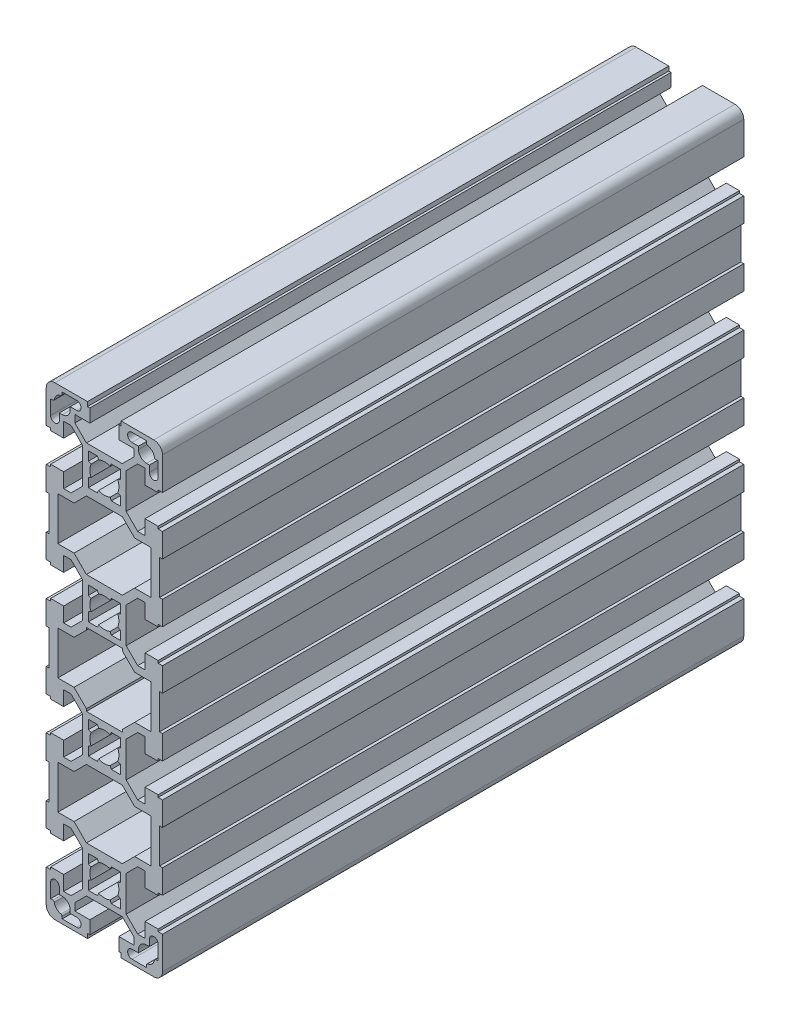
from build123d import *

# Parameters (mm, degrees)
EXTRUDE1_DEPTH = 200


with BuildPart() as part:
    # Sketch1 → Extrude1 (new body)
    with BuildSketch(Plane.XY):
        with BuildLine():
            Line((19, -34), (20, -34))
            Line((20, -34), (20, -25.8))
            Line((20, -25.8), (18.5, -25.8))
            Line((18.5, -25.8), (18.5, -25))
            Line((18.5, -25), (14, -25))
            Line((14, -25), (14, -30.05))
            Line((14, -30.05), (11.464213562, -30.05))
            Line((11.464213562, -30.05), (7.5, -26.085786438))
            Line((7.5, -26.085786438), (7.5, -13.914213562))
            Line((7.5, -13.914213562), (11.464213562, -9.95))
            Line((11.464213562, -9.95), (14, -9.95))
            Line((14, -9.95), (14, -15))
            Line((14, -15), (18.5, -15))
            Line((18.5, -15), (18.5, -14.2))
            Line((18.5, -14.2), (20, -14.2))
            Line((20, -14.2), (20, -6))
            Line((20, -6), (19, -6))
            Line((19, -6), (19, 6))
            Line((19, 6), (20, 6))
            Line((20, 6), (20, 14.2))
            Line((20, 14.2), (18.5, 14.2))
            Line((18.5, 14.2), (18.5, 15))
            Line((18.5, 15), (14, 15))
            Line((14, 15), (14, 9.95))
            Line((14, 9.95), (11.464213562, 9.95))
            Line((11.464213562, 9.95), (7.5, 13.914213562))
            Line((7.5, 13.914213562), (7.5, 26.085786438))
            Line((7.5, 26.085786438), (11.464213562, 30.05))
            Line((11.464213562, 30.05), (14, 30.05))
            Line((14, 30.05), (14, 25))
            Line((14, 25), (18.5, 25))
            Line((18.5, 25), (18.5, 25.8))
            Line((18.5, 25.8), (20, 25.8))
            Line((20, 25.8), (20, 34))
            Line((20, 34), (19, 34))
            Line((19, 34), (19, 46))
            Line((19, 46), (20, 46))
            Line((20, 46), (20, 54.2))
            Line((20, 54.2), (18.5, 54.2))
            Line((18.5, 54.2), (18.5, 55))
            Line((18.5, 55), (14, 55))
            Line((14, 55), (14, 49.95))
            Line((14, 49.95), (11.464213562, 49.95))
            Line((11.464213562, 49.95), (7.5, 53.914213562))
            Line((7.5, 53.914213562), (7.5, 66.085786438))
            Line((7.5, 66.085786438), (11.464213562, 70.05))
            Line((11.464213562, 70.05), (14, 70.05))
            Line((14, 70.05), (14, 65))
            Line((14, 65), (18.5, 65))
            Line((18.5, 65), (18.5, 65.8))
            Line((18.5, 65.8), (20, 65.8))
            Line((20, 65.8), (20, 77))
            ThreePointArc((20, 77), (19.121320344, 79.121320344), (17, 80))
            Line((17, 80), (5.8, 80))
            Line((5.8, 80), (5.8, 78.5))
            Line((5.8, 78.5), (5, 78.5))
            Line((5, 78.5), (5, 73.994624839))
            Line((5, 73.994624839), (10.142893219, 73.994624839))
            Line((10.142893219, 73.994624839), (10.142893219, 71.458838401))
            Line((10.142893219, 71.458838401), (6.178679656, 67.494624839))
            Line((6.178679656, 67.494624839), (-6.178679656, 67.494624839))
            Line((-6.178679656, 67.494624839), (-10.142893219, 71.458838401))
            Line((-10.142893219, 71.458838401), (-10.142893219, 73.994624839))
            Line((-10.142893219, 73.994624839), (-5, 73.994624839))
            Line((-5, 73.994624839), (-5, 78.5))
            Line((-5, 78.5), (-5.8, 78.5))
            Line((-5.8, 78.5), (-5.8, 80))
            Line((-5.8, 80), (-17, 80))
            ThreePointArc((-17, 80), (-19.121320344, 79.121320344), (-20, 77))
            Line((-20, 77), (-20, 65.8))
            Line((-20, 65.8), (-18.5, 65.8))
            Line((-18.5, 65.8), (-18.5, 65))
            Line((-18.5, 65), (-14, 65))
            Line((-14, 65), (-14, 70.05))
            Line((-14, 70.05), (-11.464213562, 70.05))
            Line((-11.464213562, 70.05), (-7.5, 66.085786438))
            Line((-7.5, 66.085786438), (-7.5, 53.914213562))
            Line((-7.5, 53.914213562), (-11.464213562, 49.95))
            Line((-11.464213562, 49.95), (-14, 49.95))
            Line((-14, 49.95), (-14, 55))
            Line((-14, 55), (-18.5, 55))
            Line((-18.5, 55), (-18.5, 54.2))
            Line((-18.5, 54.2), (-20, 54.2))
            Line((-20, 54.2), (-20, 46))
            Line((-20, 46), (-19, 46))
            Line((-19, 46), (-19, 34))
            Line((-19, 34), (-20, 34))
            Line((-20, 34), (-20, 25.8))
            Line((-20, 25.8), (-18.5, 25.8))
            Line((-18.5, 25.8), (-18.5, 25))
            Line((-18.5, 25), (-14, 25))
            Line((-14, 25), (-14, 30.05))
            Line((-14, 30.05), (-11.464213562, 30.05))
            Line((-11.464213562, 30.05), (-7.5, 26.085786438))
            Line((-7.5, 26.085786438), (-7.5, 13.914213562))
            Line((-7.5, 13.914213562), (-11.464213562, 9.95))
            Line((-11.464213562, 9.95), (-14, 9.95))
            Line((-14, 9.95), (-14, 15))
            Line((-14, 15), (-18.5, 15))
            Line((-18.5, 15), (-18.5, 14.2))
            Line((-18.5, 14.2), (-20, 14.2))
            Line((-20, 14.2), (-20, 6))
            Line((-20, 6), (-19, 6))
            Line((-19, 6), (-19, -6))
            Line((-19, -6), (-20, -6))
            Line((-20, -6), (-20, -14.2))
            Line((-20, -14.2), (-18.5, -14.2))
            Line((-18.5, -14.2), (-18.5, -15))
            Line((-18.5, -15), (-14, -15))
            Line((-14, -15), (-14, -9.95))
            Line((-14, -9.95), (-11.464213562, -9.95))
            Line((-11.464213562, -9.95), (-7.5, -13.914213562))
            Line((-7.5, -13.914213562), (-7.5, -26.085786438))
            Line((-7.5, -26.085786438), (-11.464213562, -30.05))
            Line((-11.464213562, -30.05), (-14, -30.05))
            Line((-14, -30.05), (-14, -25))
            Line((-14, -25), (-18.5, -25))
            Line((-18.5, -25), (-18.5, -25.8))
            Line((-18.5, -25.8), (-20, -25.8))
            Line((-20, -25.8), (-20, -34))
            Line((-20, -34), (-19, -34))
            Line((-19, -34), (-19, -46))
            Line((-19, -46), (-20, -46))
            Line((-20, -46), (-20, -54.2))
            Line((-20, -54.2), (-18.5, -54.2))
            Line((-18.5, -54.2), (-18.5, -55))
            Line((-18.5, -55), (-14, -55))
            Line((-14, -55), (-14, -49.95))
            Line((-14, -49.95), (-11.464213562, -49.95))
            Line((-11.464213562, -49.95), (-7.5, -53.914213562))
            Line((-7.5, -53.914213562), (-7.5, -66.085786438))
            Line((-7.5, -66.085786438), (-11.464213562, -70.05))
            Line((-11.464213562, -70.05), (-14, -70.05))
            Line((-14, -70.05), (-14, -65))
            Line((-14, -65), (-18.5, -65))
            Line((-18.5, -65), (-18.5, -65.8))
            Line((-18.5, -65.8), (-20, -65.8))
            Line((-20, -65.8), (-20, -77))
            ThreePointArc((-20, -77), (-19.121320344, -79.121320344), (-17, -80))
            Line((-17, -80), (-5.8, -80))
            Line((-5.8, -80), (-5.8, -78.5))
            Line((-5.8, -78.5), (-5, -78.5))
            Line((-5, -78.5), (-5, -73.994624839))
            Line((-5, -73.994624839), (-10.142893219, -73.994624839))
            Line((-10.142893219, -73.994624839), (-10.142893219, -71.458838401))
            Line((-10.142893219, -71.458838401), (-6.178679656, -67.494624839))
            Line((-6.178679656, -67.494624839), (6.178679656, -67.494624839))
            Line((6.178679656, -67.494624839), (10.142893219, -71.458838401))
            Line((10.142893219, -71.458838401), (10.142893219, -73.994624839))
            Line((10.142893219, -73.994624839), (5, -73.994624839))
            Line((5, -73.994624839), (5, -78.5))
            Line((5, -78.5), (5.8, -78.5))
            Line((5.8, -78.5), (5.8, -80))
            Line((5.8, -80), (17, -80))
            ThreePointArc((17, -80), (19.121320344, -79.121320344), (20, -77))
            Line((20, -77), (20, -65.8))
            Line((20, -65.8), (18.5, -65.8))
            Line((18.5, -65.8), (18.5, -65))
            Line((18.5, -65), (14, -65))
            Line((14, -65), (14, -70.05))
            Line((14, -70.05), (11.464213562, -70.05))
            Line((11.464213562, -70.05), (7.5, -66.085786438))
            Line((7.5, -66.085786438), (7.5, -53.914213562))
            Line((7.5, -53.914213562), (11.464213562, -49.95))
            Line((11.464213562, -49.95), (14, -49.95))
            Line((14, -49.95), (14, -55))
            Line((14, -55), (18.5, -55))
            Line((18.5, -55), (18.5, -54.2))
            Line((18.5, -54.2), (20, -54.2))
            Line((20, -54.2), (20, -46))
            Line((20, -46), (19, -46))
            Line((19, -46), (19, -34))
        make_face()
        Polygon((10.428679656, -32.55), (6.178679656, -28.3), (-6.178679656, -28.3), (-10.428679656, -32.55), (-16, -32.55), (-16, -47.45), (-10.428679656, -47.45), (-6.178679656, -51.7), (6.178679656, -51.7), (10.428679656, -47.45), (16, -47.45), (16, -32.55), align=None, mode=Mode.SUBTRACT)
        with BuildLine():
            Line((2.397915762, -25.5), (5.5, -25.5))
            Line((5.5, -25.5), (5.5, -22.397915762))
            Line((5.5, -22.397915762), (4.583333333, -21.998263135))
            ThreePointArc((4.583333333, -21.998263135), (5, -20), (4.583333333, -18.001736865))
            Line((4.583333333, -18.001736865), (5.5, -17.602084238))
            Line((5.5, -17.602084238), (5.5, -14.5))
            Line((5.5, -14.5), (2.397915762, -14.5))
            Line((2.397915762, -14.5), (1.998263135, -15.416666667))
            ThreePointArc((1.998263135, -15.416666667), (0, -15), (-1.998263135, -15.416666667))
            Line((-1.998263135, -15.416666667), (-2.397915762, -14.5))
            Line((-2.397915762, -14.5), (-5.5, -14.5))
            Line((-5.5, -14.5), (-5.5, -17.602084238))
            Line((-5.5, -17.602084238), (-4.583333333, -18.001736865))
            ThreePointArc((-4.583333333, -18.001736865), (-5, -20), (-4.583333333, -21.998263135))
            Line((-4.583333333, -21.998263135), (-5.5, -22.397915762))
            Line((-5.5, -22.397915762), (-5.5, -25.5))
            Line((-5.5, -25.5), (-2.397915762, -25.5))
            Line((-2.397915762, -25.5), (-1.998263135, -24.583333333))
            ThreePointArc((-1.998263135, -24.583333333), (0, -25), (1.998263135, -24.583333333))
            Line((1.998263135, -24.583333333), (2.397915762, -25.5))
        make_face(mode=Mode.SUBTRACT)
        Polygon((10.428679656, -7.45), (6.178679656, -11.7), (6.178679656, -12.505375161), (-6.178679656, -12.505375161), (-6.178679656, -11.7), (-10.428679656, -7.45), (-16, -7.45), (-16, 7.45), (-10.428679656, 7.45), (-6.178679656, 11.7), (-6.178679656, 12.505375161), (6.178679656, 12.505375161), (6.178679656, 11.7), (10.428679656, 7.45), (16, 7.45), (16, -7.45), align=None, mode=Mode.SUBTRACT)
        Polygon((16, 32.55), (16, 47.45), (10.428679656, 47.45), (6.178679656, 51.7), (-6.178679656, 51.7), (-10.428679656, 47.45), (-16, 47.45), (-16, 32.55), (-10.428679656, 32.55), (-6.178679656, 28.3), (6.178679656, 28.3), (10.428679656, 32.55), align=None, mode=Mode.SUBTRACT)
        with BuildLine():
            Line((18.5, 74.5), (17.711308145, 74.5))
            ThreePointArc((17.711308145, 74.5), (17.386086327, 74.620222737), (17.217260738, 74.923076923))
            ThreePointArc((17.217260738, 74.923076923), (16.444543648, 76.444543648), (14.923076923, 77.217260738))
            ThreePointArc((14.923076923, 77.217260738), (14.620222737, 77.386086327), (14.5, 77.711308145))
            Line((14.5, 77.711308145), (14.5, 78.5))
            Line((14.5, 78.5), (9.5, 78.5))
            ThreePointArc((9.5, 78.5), (8, 77), (9.5, 75.5))
            Line((9.5, 75.5), (11.75, 75.5))
            Line((11.75, 75.5), (11.75, 74.5))
            ThreePointArc((11.75, 74.5), (12.555456352, 72.555456352), (14.5, 71.75))
            Line((14.5, 71.75), (15.5, 71.75))
            Line((15.5, 71.75), (15.5, 69.5))
            ThreePointArc((15.5, 69.5), (17, 68), (18.5, 69.5))
            Line((18.5, 69.5), (18.5, 74.5))
        make_face(mode=Mode.SUBTRACT)
        with BuildLine():
            Line((2.397915762, 54.5), (5.5, 54.5))
            Line((5.5, 54.5), (5.5, 57.602084238))
            Line((5.5, 57.602084238), (4.583333333, 58.001736865))
            ThreePointArc((4.583333333, 58.001736865), (5, 60), (4.583333333, 61.998263135))
            Line((4.583333333, 61.998263135), (5.5, 62.397915762))
            Line((5.5, 62.397915762), (5.5, 65.5))
            Line((5.5, 65.5), (2.397915762, 65.5))
            Line((2.397915762, 65.5), (1.998263135, 64.583333333))
            ThreePointArc((1.998263135, 64.583333333), (0, 65), (-1.998263135, 64.583333333))
            Line((-1.998263135, 64.583333333), (-2.397915762, 65.5))
            Line((-2.397915762, 65.5), (-5.5, 65.5))
            Line((-5.5, 65.5), (-5.5, 62.397915762))
            Line((-5.5, 62.397915762), (-4.583333333, 61.998263135))
            ThreePointArc((-4.583333333, 61.998263135), (-5, 60), (-4.583333333, 58.001736865))
            Line((-4.583333333, 58.001736865), (-5.5, 57.602084238))
            Line((-5.5, 57.602084238), (-5.5, 54.5))
            Line((-5.5, 54.5), (-2.397915762, 54.5))
            Line((-2.397915762, 54.5), (-1.998263135, 55.416666667))
            ThreePointArc((-1.998263135, 55.416666667), (0, 55), (1.998263135, 55.416666667))
            Line((1.998263135, 55.416666667), (2.397915762, 54.5))
        make_face(mode=Mode.SUBTRACT)
        with BuildLine():
            Line((-17.711308145, 74.5), (-18.5, 74.5))
            Line((-18.5, 74.5), (-18.5, 69.5))
            ThreePointArc((-18.5, 69.5), (-17, 68), (-15.5, 69.5))
            Line((-15.5, 69.5), (-15.5, 71.75))
            Line((-15.5, 71.75), (-14.5, 71.75))
            ThreePointArc((-14.5, 71.75), (-12.555456352, 72.555456352), (-11.75, 74.5))
            Line((-11.75, 74.5), (-11.75, 75.5))
            Line((-11.75, 75.5), (-9.5, 75.5))
            ThreePointArc((-9.5, 75.5), (-8, 77), (-9.5, 78.5))
            Line((-9.5, 78.5), (-14.5, 78.5))
            Line((-14.5, 78.5), (-14.5, 77.711308145))
            ThreePointArc((-14.5, 77.711308145), (-14.620222737, 77.386086327), (-14.923076923, 77.217260738))
            ThreePointArc((-14.923076923, 77.217260738), (-16.444543648, 76.444543648), (-17.217260738, 74.923076923))
            ThreePointArc((-17.217260738, 74.923076923), (-17.386086327, 74.620222737), (-17.711308145, 74.5))
        make_face(mode=Mode.SUBTRACT)
        with BuildLine():
            Line((5.5, 17.602084238), (5.5, 14.5))
            Line((5.5, 14.5), (2.397915762, 14.5))
            Line((2.397915762, 14.5), (1.998263135, 15.416666667))
            ThreePointArc((1.998263135, 15.416666667), (0, 15), (-1.998263135, 15.416666667))
            Line((-1.998263135, 15.416666667), (-2.397915762, 14.5))
            Line((-2.397915762, 14.5), (-5.5, 14.5))
            Line((-5.5, 14.5), (-5.5, 17.602084238))
            Line((-5.5, 17.602084238), (-4.583333333, 18.001736865))
            ThreePointArc((-4.583333333, 18.001736865), (-5, 20), (-4.583333333, 21.998263135))
            Line((-4.583333333, 21.998263135), (-5.5, 22.397915762))
            Line((-5.5, 22.397915762), (-5.5, 25.5))
            Line((-5.5, 25.5), (-2.397915762, 25.5))
            Line((-2.397915762, 25.5), (-1.998263135, 24.583333333))
            ThreePointArc((-1.998263135, 24.583333333), (0, 25), (1.998263135, 24.583333333))
            Line((1.998263135, 24.583333333), (2.397915762, 25.5))
            Line((2.397915762, 25.5), (5.5, 25.5))
            Line((5.5, 25.5), (5.5, 22.397915762))
            Line((5.5, 22.397915762), (4.583333333, 21.998263135))
            ThreePointArc((4.583333333, 21.998263135), (5, 20), (4.583333333, 18.001736865))
            Line((4.583333333, 18.001736865), (5.5, 17.602084238))
        make_face(mode=Mode.SUBTRACT)
        with BuildLine():
            Line((14.5, -78.5), (9.5, -78.5))
            ThreePointArc((9.5, -78.5), (8, -77), (9.5, -75.5))
            Line((9.5, -75.5), (11.75, -75.5))
            Line((11.75, -75.5), (11.75, -74.5))
            ThreePointArc((11.75, -74.5), (12.555456352, -72.555456352), (14.5, -71.75))
            Line((14.5, -71.75), (15.5, -71.75))
            Line((15.5, -71.75), (15.5, -69.5))
            ThreePointArc((15.5, -69.5), (17, -68), (18.5, -69.5))
            Line((18.5, -69.5), (18.5, -74.5))
            Line((18.5, -74.5), (17.711308145, -74.5))
            ThreePointArc((17.711308145, -74.5), (17.386086327, -74.620222737), (17.217260738, -74.923076923))
            ThreePointArc((17.217260738, -74.923076923), (16.444543648, -76.444543648), (14.923076923, -77.217260738))
            ThreePointArc((14.923076923, -77.217260738), (14.620222737, -77.386086327), (14.5, -77.711308145))
            Line((14.5, -77.711308145), (14.5, -78.5))
        make_face(mode=Mode.SUBTRACT)
        with BuildLine():
            Line((-9.5, -78.5), (-14.5, -78.5))
            Line((-14.5, -78.5), (-14.5, -77.711308145))
            ThreePointArc((-14.5, -77.711308145), (-14.620222737, -77.386086327), (-14.923076923, -77.217260738))
            ThreePointArc((-14.923076923, -77.217260738), (-16.444543648, -76.444543648), (-17.217260738, -74.923076923))
            ThreePointArc((-17.217260738, -74.923076923), (-17.386086327, -74.620222737), (-17.711308145, -74.5))
            Line((-17.711308145, -74.5), (-18.5, -74.5))
            Line((-18.5, -74.5), (-18.5, -69.5))
            ThreePointArc((-18.5, -69.5), (-17, -68), (-15.5, -69.5))
            Line((-15.5, -69.5), (-15.5, -71.75))
            Line((-15.5, -71.75), (-14.5, -71.75))
            ThreePointArc((-14.5, -71.75), (-12.555456352, -72.555456352), (-11.75, -74.5))
            Line((-11.75, -74.5), (-11.75, -75.5))
            Line((-11.75, -75.5), (-9.5, -75.5))
            ThreePointArc((-9.5, -75.5), (-8, -77), (-9.5, -78.5))
        make_face(mode=Mode.SUBTRACT)
        with BuildLine():
            Line((5.5, -62.397915762), (5.5, -65.5))
            Line((5.5, -65.5), (2.397915762, -65.5))
            Line((2.397915762, -65.5), (1.998263135, -64.583333333))
            ThreePointArc((1.998263135, -64.583333333), (0, -65), (-1.998263135, -64.583333333))
            Line((-1.998263135, -64.583333333), (-2.397915762, -65.5))
            Line((-2.397915762, -65.5), (-5.5, -65.5))
            Line((-5.5, -65.5), (-5.5, -62.397915762))
            Line((-5.5, -62.397915762), (-4.583333333, -61.998263135))
            ThreePointArc((-4.583333333, -61.998263135), (-5, -60), (-4.583333333, -58.001736865))
            Line((-4.583333333, -58.001736865), (-5.5, -57.602084238))
            Line((-5.5, -57.602084238), (-5.5, -54.5))
            Line((-5.5, -54.5), (-2.397915762, -54.5))
            Line((-2.397915762, -54.5), (-1.998263135, -55.416666667))
            ThreePointArc((-1.998263135, -55.416666667), (0, -55), (1.998263135, -55.416666667))
            Line((1.998263135, -55.416666667), (2.397915762, -54.5))
            Line((2.397915762, -54.5), (5.5, -54.5))
            Line((5.5, -54.5), (5.5, -57.602084238))
            Line((5.5, -57.602084238), (4.583333333, -58.001736865))
            ThreePointArc((4.583333333, -58.001736865), (5, -60), (4.583333333, -61.998263135))
            Line((4.583333333, -61.998263135), (5.5, -62.397915762))
        make_face(mode=Mode.SUBTRACT)
    extrude(amount=-EXTRUDE1_DEPTH)


solid = part.part
